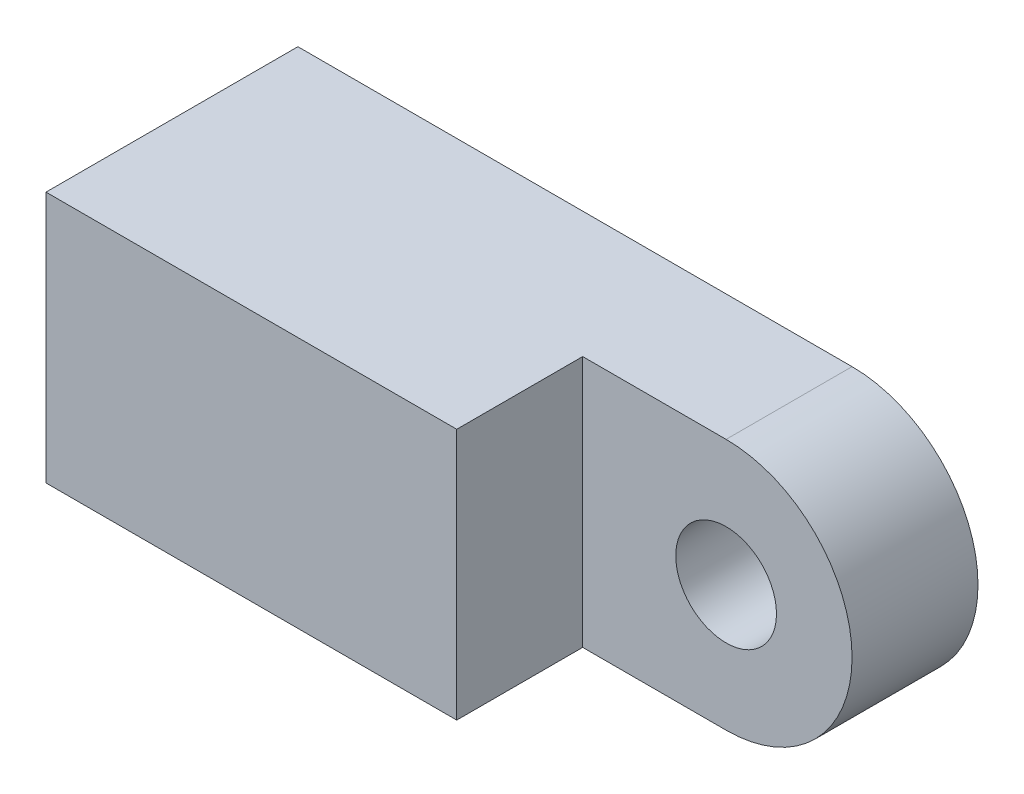
from build123d import *

# Parameters (mm, degrees)
BOSS_EXTRUDE1_DEPTH = 10
SKETCH2_R           = 2
CUT_EXTRUDE1_DEPTH  = 30
SKETCH4_W           = 18.757466853
SKETCH4_H           = 10.0829174
CUT_EXTRUDE3_DEPTH  = 5


with BuildPart() as part:
    # Sketch1 → Boss-Extrude1 (new body)
    with BuildSketch(Plane.XY):
        with BuildLine():
            Line((0, -10.891659923), (2, -10.891659923))
            ThreePointArc((2, -10.891659923), (7, -5.891659923), (2, -0.891659923))
            Line((2, -0.891659923), (-20, -0.891659923))
            Line((-20, -0.891659923), (-20, -10.891659923))
            Line((-20, -10.891659923), (0, -10.891659923))
        make_face()
    extrude(amount=BOSS_EXTRUDE1_DEPTH)

    # Sketch2 → Cut-Extrude1 (cut)
    with BuildSketch(Plane.XY.offset(10)):
        with Locations((2, -5.891659923)):
            Circle(SKETCH2_R)
    extrude(amount=-CUT_EXTRUDE1_DEPTH, mode=Mode.SUBTRACT)

    # Sketch4 → Cut-Extrude3 (cut)
    with BuildSketch(Plane.XY.offset(10)):
        with Locations((5.685057141, -5.933118623)):
            Rectangle(SKETCH4_W, SKETCH4_H)
    extrude(amount=-CUT_EXTRUDE3_DEPTH, mode=Mode.SUBTRACT)


solid = part.part
